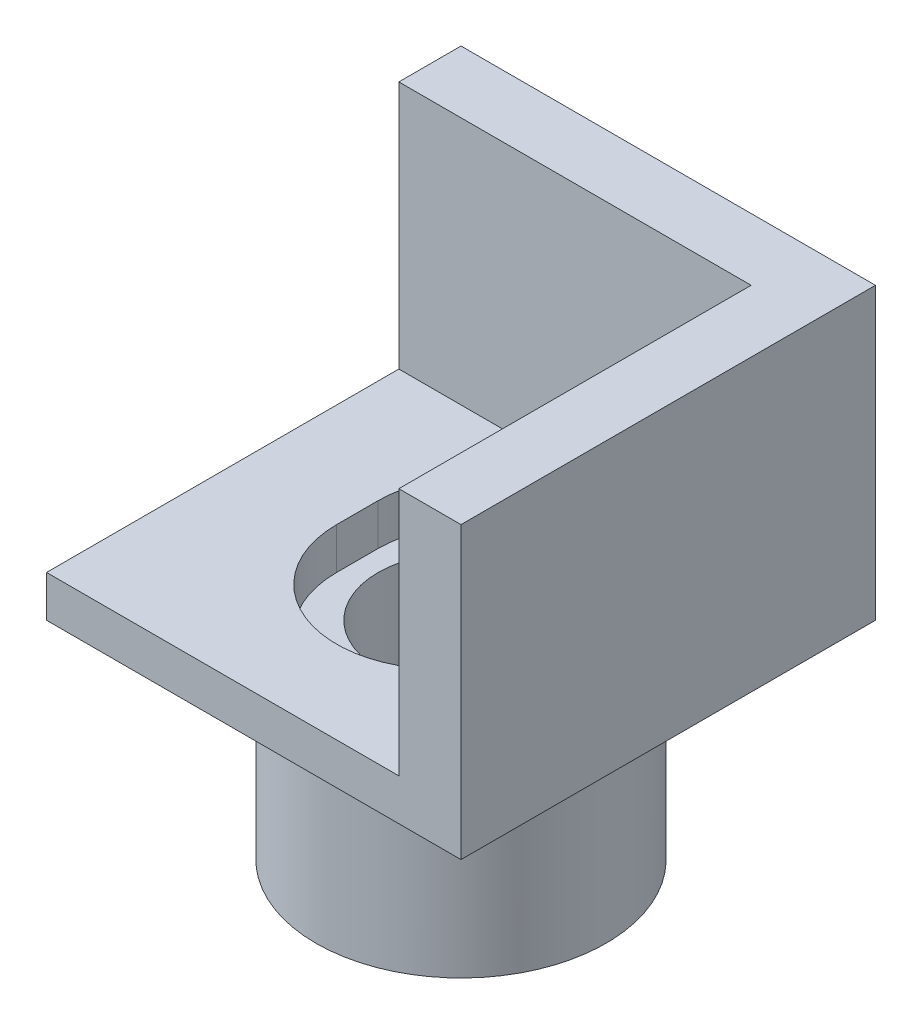
from build123d import *

# Parameters (mm, degrees)
SKETCH1_W           = 10
SKETCH1_H           = 10
BOSS_EXTRUDE1_DEPTH = 1
CUT_EXTRUDE1_DEPTH  = 1.5
SKETCH3_R           = 3.5
BOSS_EXTRUDE2_DEPTH = 5
SKETCH4_R           = 2
CUT_EXTRUDE2_DEPTH  = 6
BOSS_EXTRUDE3_DEPTH = 6


with BuildPart() as part:
    # Sketch1 → Boss-Extrude1 (new body)
    with BuildSketch(Plane(origin=(0, 0, 0), x_dir=(1, 0, 0), z_dir=(0, 1, 0))):
        Rectangle(SKETCH1_W, SKETCH1_H)
    extrude(amount=BOSS_EXTRUDE1_DEPTH)

    # Sketch2 → Cut-Extrude1 (cut)
    with BuildSketch(Plane(origin=(0, 1, 0), x_dir=(1, 0, 0), z_dir=(0, 1, 0))):
        with BuildLine():
            Line((2.5, 0.5), (2.5, -0.5))
            ThreePointArc((2.5, -0.5), (0, -3), (-2.5, -0.5))
            Line((-2.5, -0.5), (-2.5, 0.5))
            ThreePointArc((-2.5, 0.5), (0, 3), (2.5, 0.5))
        make_face()
    extrude(amount=-CUT_EXTRUDE1_DEPTH, mode=Mode.SUBTRACT)

    # Sketch3 → Boss-Extrude2 (add)
    with BuildSketch(Plane.XZ):
        Circle(SKETCH3_R)
    extrude(amount=BOSS_EXTRUDE2_DEPTH)

    # Sketch4 → Cut-Extrude2 (cut, through all)
    with BuildSketch(Plane(origin=(0, 0, 0), x_dir=(1, 0, 0), z_dir=(0, 1, 0))):
        Circle(SKETCH4_R)
    extrude(amount=-CUT_EXTRUDE2_DEPTH, mode=Mode.SUBTRACT)

    # Sketch6 → Boss-Extrude3 (add)
    with BuildSketch(Plane(origin=(0, 1, 0), x_dir=(1, 0, 0), z_dir=(0, 1, 0))):
        Polygon((3.5, -5), (3.5, 3.5), (-5, 3.5), (-5, 5), (5, 5), (5, -5), align=None)
    extrude(amount=BOSS_EXTRUDE3_DEPTH)


solid = part.part
